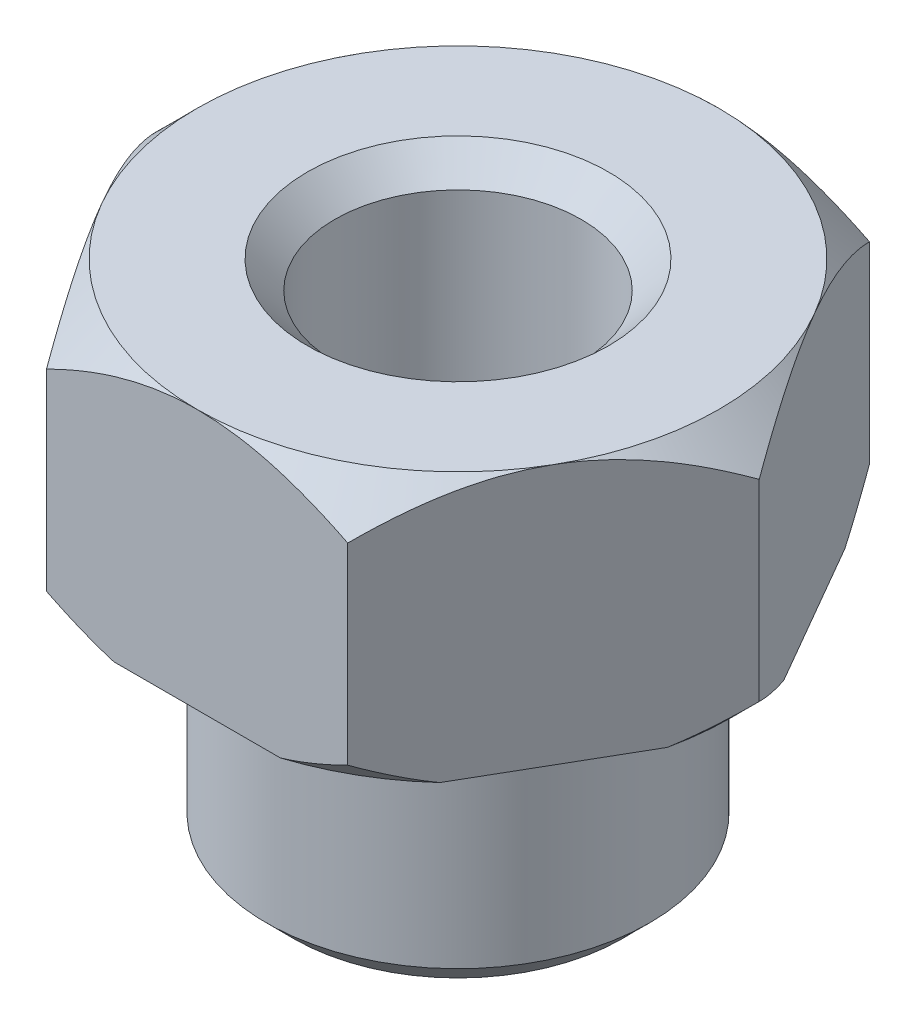
from build123d import *

# Parameters (mm, degrees)
CROQUIS4_OUTSIDE_W    = 60.478
CROQUIS4_OUTSIDE_H    = 60.478
CORTAR_EXTRUIR6_DEPTH = 70
CROQUIS5_OUTSIDE_W    = 199.794
CROQUIS5_OUTSIDE_H    = 193.9
CROQUIS5_OUTSIDE_R    = 19.052558883
CORTAR_EXTRUIR7_DEPTH = 70
CORTAR_EXTRUIR7_TAPER = 45
CROQUIS6_R            = 9
CORTAR_EXTRUIR8_DEPTH = 15
CHAFL_N1_SIZE         = 2
REDONDEO1_R           = 1


with BuildPart() as part:
    # Croquis1 → Revolución1 (revolve)
    with BuildSketch(Plane.XY):
        Polygon((6.35, 31.379194031), (20, 31.379194031), (22, 29.379194031), (22, 14.379194031), (20, 12.379194031), (14, 12.379194031), (13.076641816, 12.379194031), (13.076641816, 9.706334079), (14, 9.020543495), (14, -3.620805969), (12, -5.620805969), (1.5875, -5.620805969), (1.5875, 12.379194031), (6.35, 12.379194031), align=None)
    revolve(axis=Axis((0, 51.930492424, 0), (0, -1, 0)))

    # Croquis4 outside → Cortar-Extruir6 (cut)
    with BuildSketch(Plane(origin=(0, 31.379194031, 0), x_dir=(1, 0, 0), z_dir=(0, 1, 0))):
        Rectangle(CROQUIS4_OUTSIDE_W, CROQUIS4_OUTSIDE_H)
        Polygon((22, 0), (11, 19.052558883), (-11, 19.052558883), (-22, 0), (-11, -19.052558883), (11, -19.052558883), align=None, mode=Mode.SUBTRACT)
    extrude(amount=-CORTAR_EXTRUIR6_DEPTH, mode=Mode.SUBTRACT)

    # Croquis5 outside → Cortar-Extruir7 (cut)
    with BuildSketch(Plane(origin=(0, 31.379194031, 0), x_dir=(1, 0, 0), z_dir=(0, 1, 0))):
        Rectangle(CROQUIS5_OUTSIDE_W, CROQUIS5_OUTSIDE_H)
        Circle(CROQUIS5_OUTSIDE_R, mode=Mode.SUBTRACT)
    extrude(amount=-CORTAR_EXTRUIR7_DEPTH, taper=CORTAR_EXTRUIR7_TAPER, mode=Mode.SUBTRACT)

    # Croquis6 → Cortar-Extruir8 (cut)
    with BuildSketch(Plane(origin=(0, 31.379194031, 0), x_dir=(1, 0, 0), z_dir=(0, 1, 0))):
        Circle(CROQUIS6_R)
    extrude(amount=-CORTAR_EXTRUIR8_DEPTH, mode=Mode.SUBTRACT)

    # Chaflán1
    chafl_n1_edges = [part.edges().sort_by_distance(p)[0] for p in [
        (-9, 31.379194031, 0),
    ]]
    chamfer(chafl_n1_edges, length=CHAFL_N1_SIZE)

    # Redondeo1
    redondeo1_edges = [part.edges().sort_by_distance(p)[0] for p in [
        (-6.35, 16.379194031, 0),
    ]]
    fillet(redondeo1_edges, radius=REDONDEO1_R)


solid = part.part
